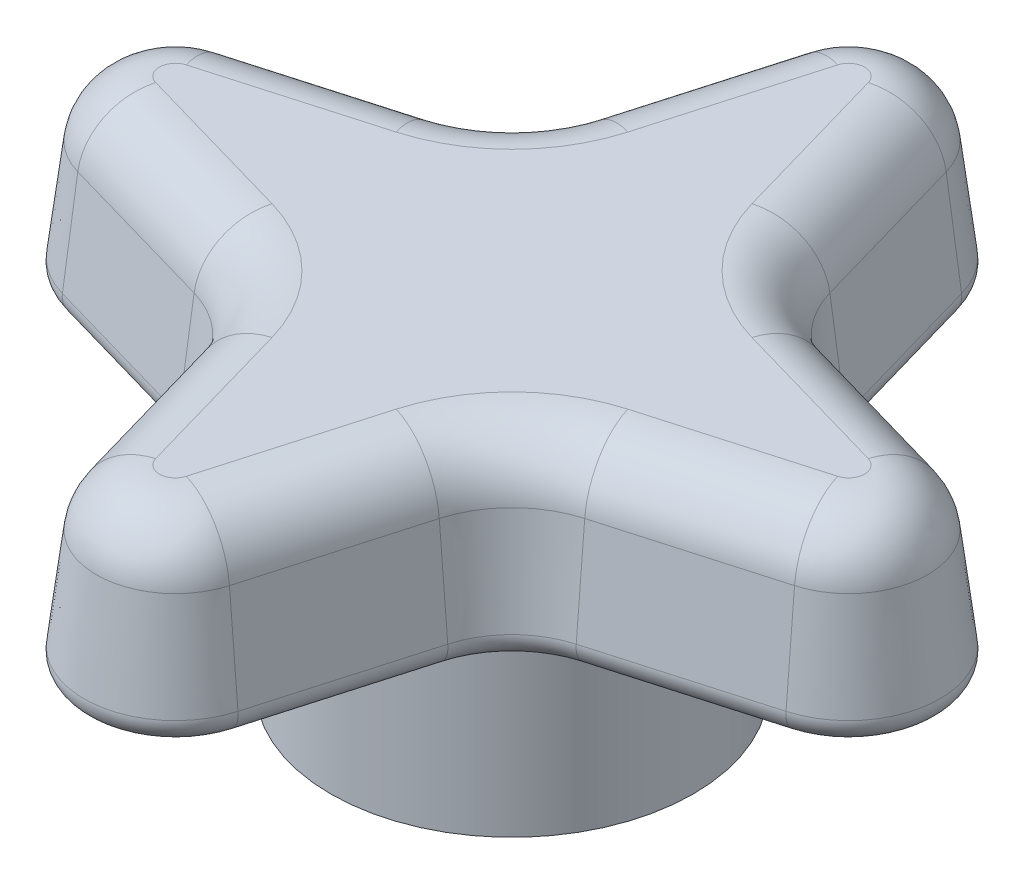
from build123d import *

# Parameters (mm, degrees)
EXTRUDE1_DEPTH = 6.35
EXTRUDE1_TAPER = 7.000000000000015
FILLET1_R      = 2.2224999999999997
SKETCH2_R      = 6.35
SKETCH2_R_2    = 4.7625
EXTRUDE2_DEPTH = 6.35
FILLET2_R      = 0.762


with BuildPart() as part:
    # Sketch1 → Extrude1 (new body)
    with BuildSketch(Plane(origin=(0, 0, 0), x_dir=(1, 0, 0), z_dir=(0, 1, 0))):
        with BuildLine():
            ThreePointArc((3.174999999999997, 12.7), (2.4e-15, 15.092534109076349), (-3.17499999999998, 12.7))
            Line((-3.17499999999998, 12.7), (-4.812500349494196, 6.989357629379411))
            ThreePointArc((-4.812500349494196, 6.989357629379411), (-5.619442203831074, 5.619442203831092), (-6.989357629379396, 4.812500349494221))
            Line((-6.989357629379396, 4.812500349494221), (-12.699999999999969, 3.1750000000000442))
            ThreePointArc((-12.699999999999969, 3.1750000000000442), (-15.092534109076396, -4e-16), (-12.699999999999969, -3.1750000000000442))
            Line((-12.699999999999969, -3.1750000000000442), (-6.989357629379396, -4.812500349494221))
            ThreePointArc((-6.989357629379396, -4.812500349494221), (-5.619442203831074, -5.619442203831092), (-4.812500349494196, -6.989357629379411))
            Line((-4.812500349494196, -6.989357629379411), (-3.17499999999998, -12.7))
            ThreePointArc((-3.17499999999998, -12.7), (3.14e-15, -15.092534109076366), (3.174999999999997, -12.7))
            Line((3.174999999999997, -12.7), (4.812500349494196, -6.989357629379411))
            ThreePointArc((4.812500349494196, -6.989357629379411), (5.619442203831074, -5.619442203831092), (6.989357629379396, -4.812500349494221))
            Line((6.989357629379396, -4.812500349494221), (12.699999999999985, -3.1750000000000442))
            ThreePointArc((12.699999999999985, -3.1750000000000442), (15.0925341090764, 0), (12.699999999999985, 3.1750000000000442))
            Line((12.699999999999985, 3.1750000000000442), (6.989357629379396, 4.812500349494221))
            ThreePointArc((6.989357629379396, 4.812500349494221), (5.619442203831074, 5.619442203831092), (4.812500349494196, 6.989357629379411))
            Line((4.812500349494196, 6.989357629379411), (3.174999999999997, 12.7))
        make_face()
    extrude(amount=EXTRUDE1_DEPTH, taper=EXTRUDE1_TAPER)

    # Fillet1
    fillet1_edges = [part.edges().sort_by_distance(p)[0] for p in [
        (-5.068123801520527, 6.35, -5.068123801520538),
        (-9.629769340379273, 6.35, -3.244271769918723),
        (-14.31285214734295, 6.35, 2.2e-16),
        (-9.629769340379273, 6.35, 3.244271769918723),
        (-5.068123801520526, 6.35, 5.06812380152054),
        (-3.2442717699186803, 6.35, 9.629769340379287),
        (1.155e-14, 6.35, 14.312852147342921),
        (3.2442717699186887, 6.35, 9.629769340379289),
        (5.068123801520522, 6.35, 5.068123801520543),
        (9.629769340379273, 6.35, 3.244271769918725),
        (1.443e-14, 6.35, -14.312852147342902),
        (14.312852147342955, 6.35, 1.33e-15),
        (9.629769340379273, 6.35, -3.2442717699187247),
        (5.068123801520526, 6.35, -5.06812380152054),
        (3.2442717699186923, 6.35, -9.629769340379278),
        (-3.2442717699186843, 6.35, -9.629769340379275),
    ]]
    fillet(fillet1_edges, radius=FILLET1_R)

    # Sketch2 → Extrude2 (add)
    with BuildSketch(Plane.XZ):
        with Locations(Location((0, 0, 0), (0, 0, 270))):
            Circle(SKETCH2_R)
        with Locations(Location((0, 0, 0), (0, 0, 270))):
            Circle(SKETCH2_R_2, mode=Mode.SUBTRACT)
    extrude(amount=EXTRUDE2_DEPTH)

    # Fillet2
    fillet2_edges = [part.edges().sort_by_distance(p)[0] for p in [
        (3.9937501747470967, 0, -9.844678814689704),
        (5.619442203831074, 0, -5.619442203831092),
        (9.84467881468969, 0, -3.9937501747471327),
        (15.0925341090764, 0, 3.3e-16),
        (9.84467881468969, 0, 3.9937501747471327),
        (5.619442203831073, 0, 5.619442203831092),
        (3.9937501747470967, 0, 9.844678814689704),
        (7.99e-15, 0, 15.092534109076366),
        (-3.993750174747088, 0, 9.844678814689704),
        (-5.619442203831074, 0, 5.619442203831092),
        (-9.844678814689683, 0, 3.9937501747471327),
        (-15.092534109076396, 0, -3.3e-16),
        (-9.844678814689683, 0, -3.9937501747471327),
        (-5.619442203831073, 0, -5.619442203831092),
        (-3.9937501747470883, 0, -9.844678814689704),
        (8.88e-15, 0, -15.092534109076349),
    ]]
    fillet(fillet2_edges, radius=FILLET2_R)


solid = part.part
